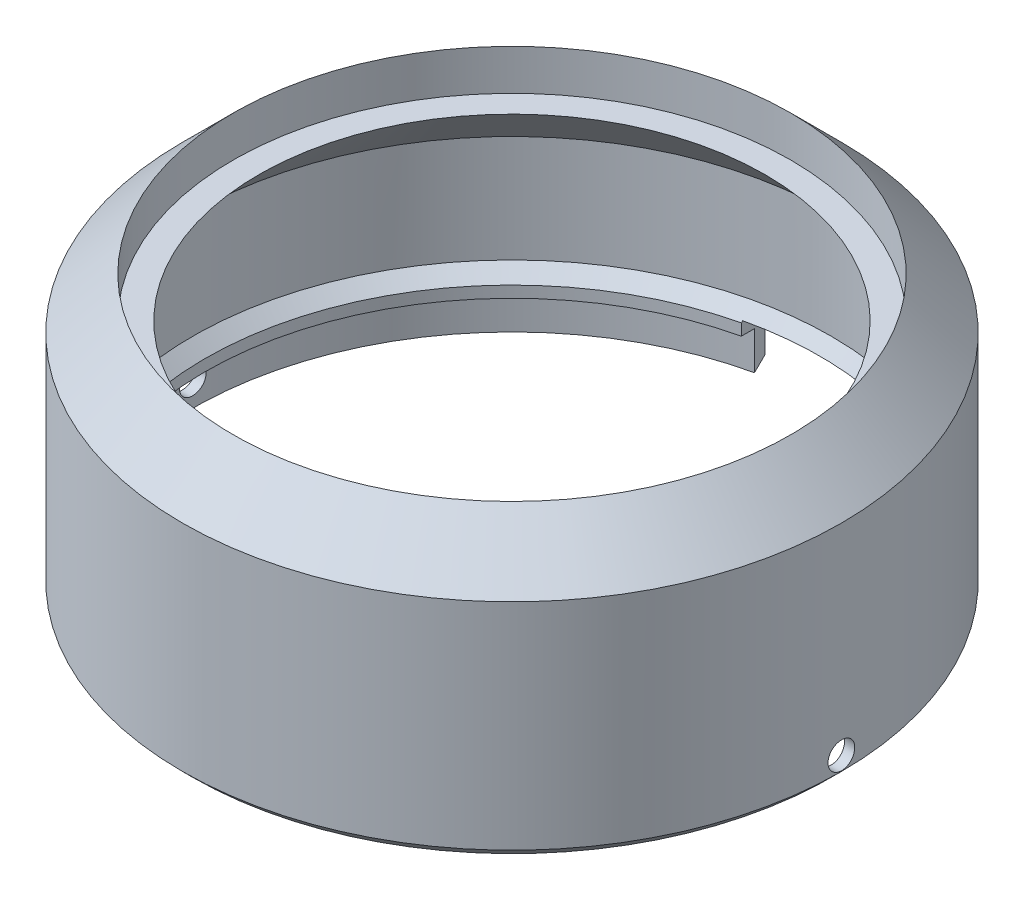
from build123d import *

# Parameters (mm, degrees)
SKETCH2_W               = 10.9
SKETCH2_H               = 4.3
CUT_EXTRUDE1_DEPTH      = 26.9
SKETCH3_R               = 1.05
CUT_EXTRUDE2_DEPTH      = 26.9
CUT_EXTRUDE2_DEPTH_BACK = 26.9


with BuildPart() as part:
    # Sketch1 → Revolve1 (revolve)
    with BuildSketch(Plane.XY):
        Polygon((25.1, 1), (24.1, 0), (24.1, -0.9), (25.1, -0.9), (25.1, -3.9), (25.9, -3.1), (25.9, 13.8), (21.9, 17.8), (21.9, 14.6), (19.9, 14.6), (25.1, 9.4), align=None)
    revolve(axis=Axis((0, -5, 0), (0, 1, 0)))

    # Sketch2 → Cut-Extrude1 (cut, through all)
    with BuildSketch(Plane.XY):
        with Locations((0, -2.05)):
            Rectangle(SKETCH2_W, SKETCH2_H)
    extrude(amount=-CUT_EXTRUDE1_DEPTH, mode=Mode.SUBTRACT)

    # Sketch3 → Cut-Extrude2 (cut, two sides)
    with BuildSketch(Plane(origin=(0, 0, 0), x_dir=(0, 0, -1), z_dir=(1, 0, 0))) as cut_extrude2_sk:
        with Locations((0, -2)):
            Circle(SKETCH3_R)
    extrude(amount=CUT_EXTRUDE2_DEPTH, mode=Mode.SUBTRACT)
    extrude(cut_extrude2_sk.sketch, amount=-CUT_EXTRUDE2_DEPTH_BACK, mode=Mode.SUBTRACT)


solid = part.part
